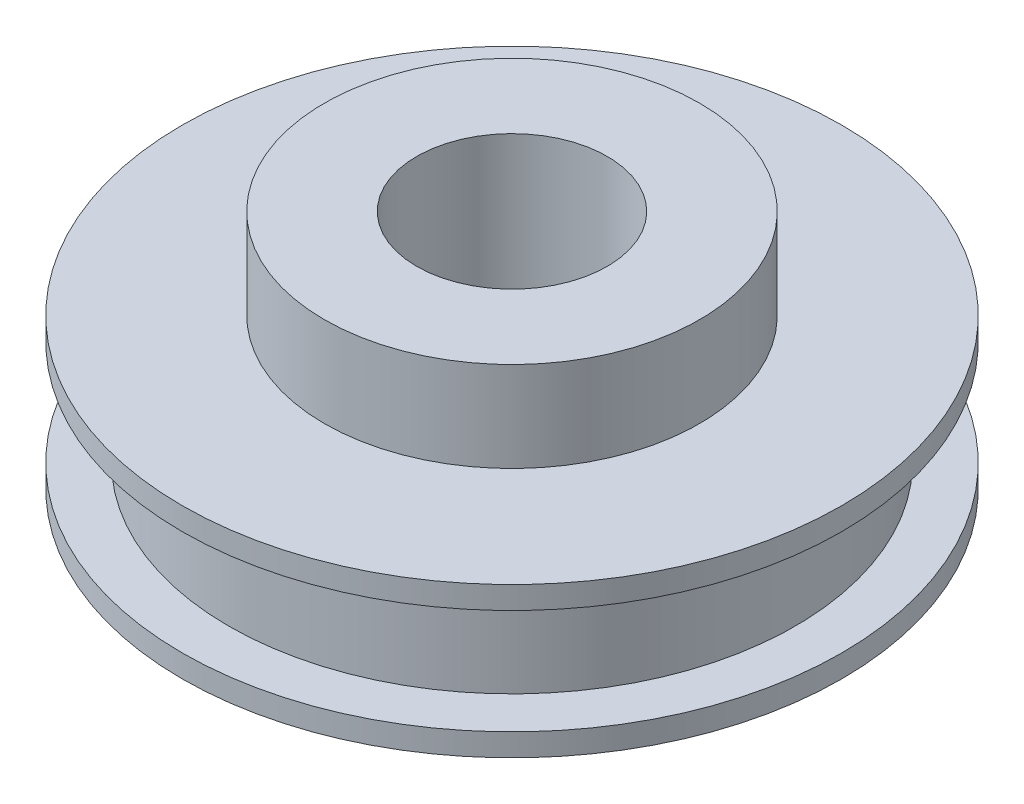
from build123d import *

# Parameters (mm, degrees)
SKETCH2_R          = 6.35
CUT_EXTRUDE1_DEPTH = 17


with BuildPart() as part:
    # Sketch1 → Revolve1 (revolve)
    with BuildSketch(Plane.XY):
        Polygon((0, 0), (0, 16), (-12.5, 16), (-12.5, 10), (-21.971, 10), (-21.971, 8.5), (-18.875, 8.5), (-18.875, 1.5), (-21.971, 1.5), (-21.971, 0), align=None)
    revolve(axis=Axis((0, 0, 0), (0, 1, 0)))

    # Sketch2 → Cut-Extrude1 (cut, through all)
    with BuildSketch(Plane(origin=(0, 16, 0), x_dir=(1, 0, 0), z_dir=(0, 1, 0))):
        Circle(SKETCH2_R)
    extrude(amount=-CUT_EXTRUDE1_DEPTH, mode=Mode.SUBTRACT)


solid = part.part
